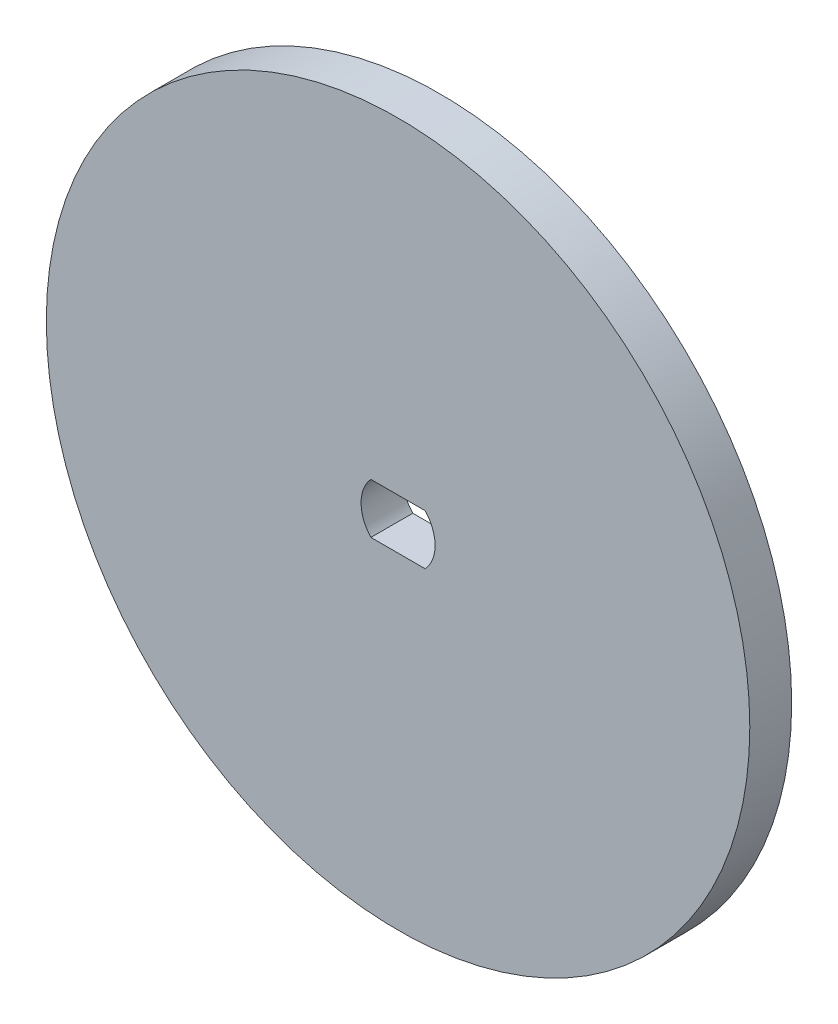
from build123d import *

# Parameters (mm, degrees)
SKETCH1_R           = 26.67
BOSS_EXTRUDE1_DEPTH = 3.175


with BuildPart() as part:
    # Sketch1 → Boss-Extrude1 (new body)
    with BuildSketch(Plane.XY):
        Circle(SKETCH1_R)
        with BuildLine():
            ThreePointArc((-2.061198654, 1.905), (-2.8067, 0), (-2.061198654, -1.905))
            Line((-2.061198654, -1.905), (2.061198654, -1.905))
            ThreePointArc((2.061198654, -1.905), (2.8067, 0), (2.061198654, 1.905))
            Line((2.061198654, 1.905), (-2.061198654, 1.905))
        make_face(mode=Mode.SUBTRACT)
    extrude(amount=BOSS_EXTRUDE1_DEPTH)


solid = part.part
